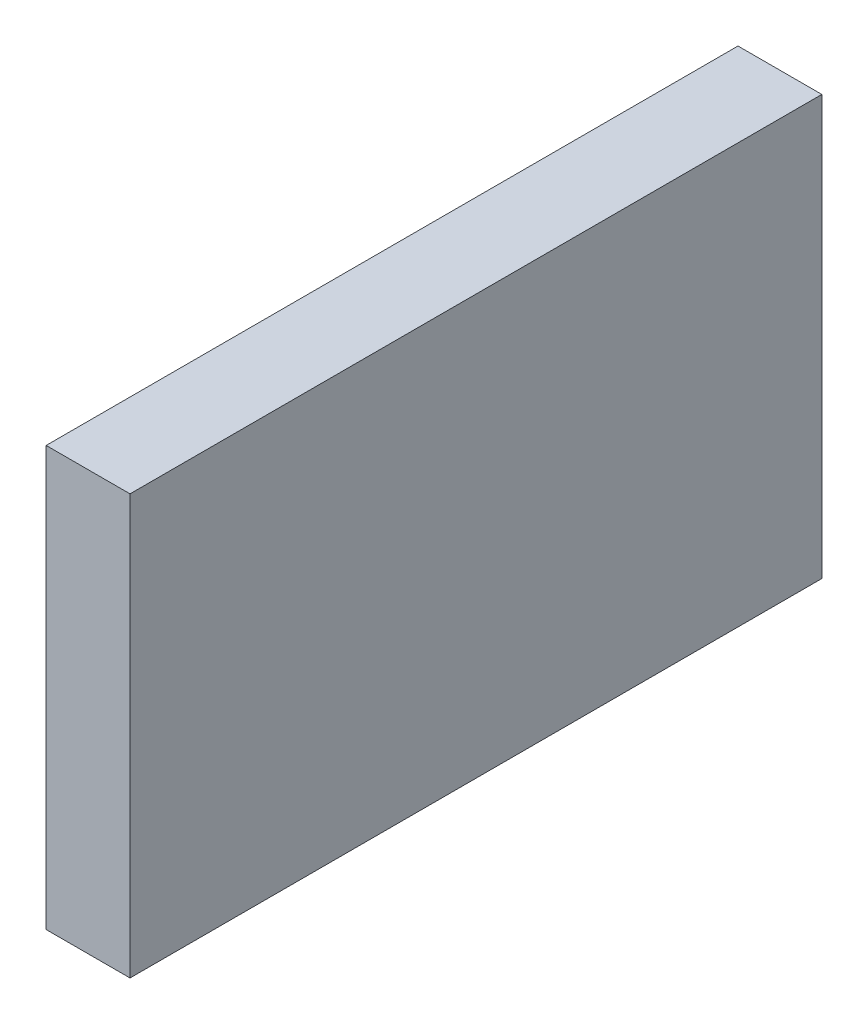
from build123d import *

# Parameters (mm, degrees)
CROQUIS1_W              = 33
CROQUIS1_H              = 20
SALIENTE_EXTRUIR1_DEPTH = 4


with BuildPart() as part:
    # Croquis1 → Saliente-Extruir1 (new body)
    with BuildSketch(Plane(origin=(0, 0, 0), x_dir=(0, 0, -1), z_dir=(1, 0, 0))):
        Rectangle(CROQUIS1_W, CROQUIS1_H)
    extrude(amount=SALIENTE_EXTRUIR1_DEPTH)


solid = part.part
